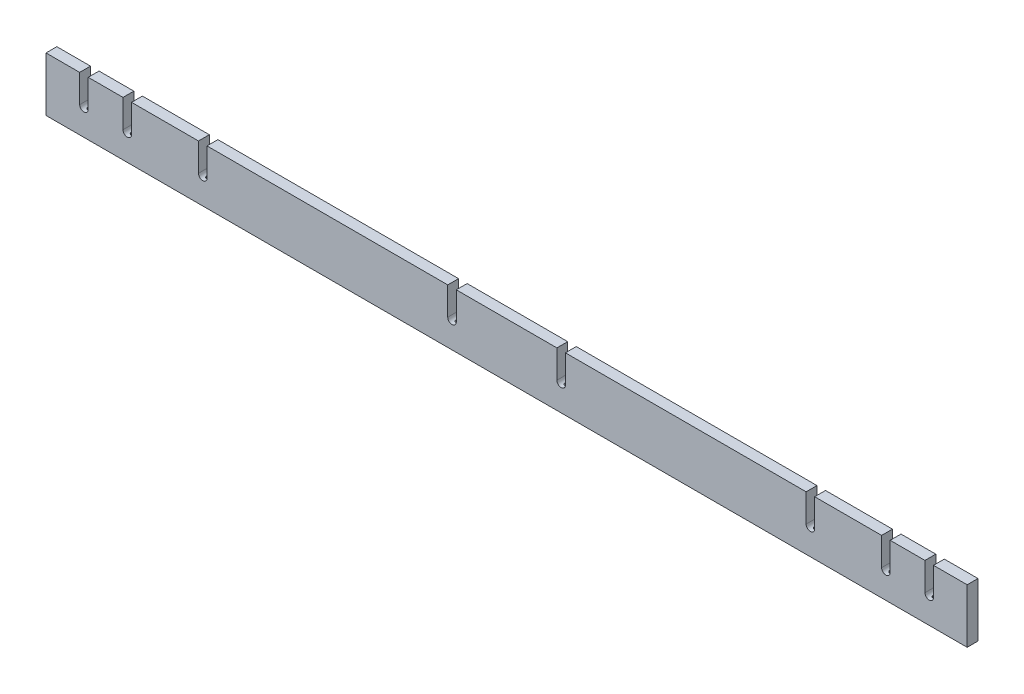
from build123d import *

# Parameters (mm, degrees)
SKETCH1_W          = 1079.5
SKETCH1_H          = 63.5
EXTRUDE1_DEPTH     = 12.7
CUT_EXTRUDE1_DEPTH = 13.7
SKETCH6_R          = 2.0828
CUT_EXTRUDE3_DEPTH = 64.5
CUT_EXTRUDE4_DEPTH = 13.7000001
SKETCH8_R          = 2.0828
CUT_EXTRUDE5_DEPTH = 64.5


with BuildPart() as part:
    # Sketch1 → Extrude1 (new body)
    with BuildSketch(Plane.XY):
        with Locations((0, 996.95)):
            Rectangle(SKETCH1_W, SKETCH1_H)
    extrude(amount=EXTRUDE1_DEPTH)

    # Sketch4 → Cut-Extrude1 (cut, through all)
    with BuildSketch(Plane(origin=(0, 0, 0), x_dir=(-1, 0, 0), z_dir=(0, 0, -1))):
        with BuildLine():
            Line((-68.95, 1028.7), (-68.95, 995.9))
            ThreePointArc((-68.95, 995.9), (-63.95, 990.9), (-58.95, 995.9))
            Line((-58.95, 995.9), (-58.95, 1028.7))
            Line((-58.95, 1028.7), (-68.95, 1028.7))
        make_face()
        with BuildLine():
            Line((-351.05, 1028.7), (-361.05, 1028.7))
            Line((-361.05, 1028.7), (-361.05, 995.9))
            ThreePointArc((-361.05, 995.9), (-356.05, 990.9), (-351.05, 995.9))
            Line((-351.05, 995.9), (-351.05, 1028.7))
        make_face()
        with BuildLine():
            Line((58.95, 1028.7), (58.95, 995.9))
            ThreePointArc((58.95, 995.9), (63.95, 990.9), (68.95, 995.9))
            Line((68.95, 995.9), (68.95, 1028.7))
            Line((68.95, 1028.7), (58.95, 1028.7))
        make_face()
        with BuildLine():
            Line((351.05, 1028.7), (351.05, 995.9))
            ThreePointArc((351.05, 995.9), (356.05, 990.9), (361.05, 995.9))
            Line((361.05, 995.9), (361.05, 1028.7))
            Line((361.05, 1028.7), (351.05, 1028.7))
        make_face()
    extrude(amount=-CUT_EXTRUDE1_DEPTH, mode=Mode.SUBTRACT)

    # Sketch6 → Cut-Extrude3 (cut, through all)
    with BuildSketch(Plane.XZ.offset(-965.2)):
        with Locations((-356.05, 6.35)):
            Circle(SKETCH6_R)
        with Locations((356.05, 6.35)):
            Circle(SKETCH6_R)
        with Locations((63.95, 6.35)):
            Circle(SKETCH6_R)
        with Locations((-63.95, 6.35)):
            Circle(SKETCH6_R)
    extrude(amount=-CUT_EXTRUDE3_DEPTH, mode=Mode.SUBTRACT)

    # Sketch7 → Cut-Extrude4 (cut, through all)
    with BuildSketch(Plane.XY.offset(12.7)):
        with BuildLine():
            Line((-449.5, 995.9), (-449.5, 1028.7))
            Line((-449.5, 1028.7), (-439.5, 1028.7))
            Line((-439.5, 1028.7), (-439.5, 995.9))
            ThreePointArc((-439.5, 995.9), (-444.5, 990.9), (-449.5, 995.9))
        make_face()
        with BuildLine():
            Line((-500.3, 995.9), (-500.3, 1028.7))
            Line((-500.3, 1028.7), (-490.3, 1028.7))
            Line((-490.3, 1028.7), (-490.3, 995.9))
            ThreePointArc((-490.3, 995.9), (-495.3, 990.9), (-500.3, 995.9))
        make_face()
        with BuildLine():
            Line((490.3, 1028.7), (490.3, 995.9))
            ThreePointArc((490.3, 995.9), (495.3, 990.9), (500.3, 995.9))
            Line((500.3, 995.9), (500.3, 1028.7))
            Line((500.3, 1028.7), (490.3, 1028.7))
        make_face()
        with BuildLine():
            Line((439.5, 1028.7), (439.5, 995.9))
            ThreePointArc((439.5, 995.9), (444.5, 990.9), (449.5, 995.9))
            Line((449.5, 995.9), (449.5, 1028.7))
            Line((449.5, 1028.7), (439.5, 1028.7))
        make_face()
    extrude(amount=-CUT_EXTRUDE4_DEPTH, mode=Mode.SUBTRACT)

    # Sketch8 → Cut-Extrude5 (cut, through all)
    with BuildSketch(Plane.XZ.offset(-965.2)):
        with Locations((-495.3, 6.35)):
            Circle(SKETCH8_R)
        with Locations((-444.5, 6.35)):
            Circle(SKETCH8_R)
        with Locations((444.5, 6.35)):
            Circle(SKETCH8_R)
        with Locations((495.3, 6.35)):
            Circle(SKETCH8_R)
    extrude(amount=-CUT_EXTRUDE5_DEPTH, mode=Mode.SUBTRACT)


solid = part.part
